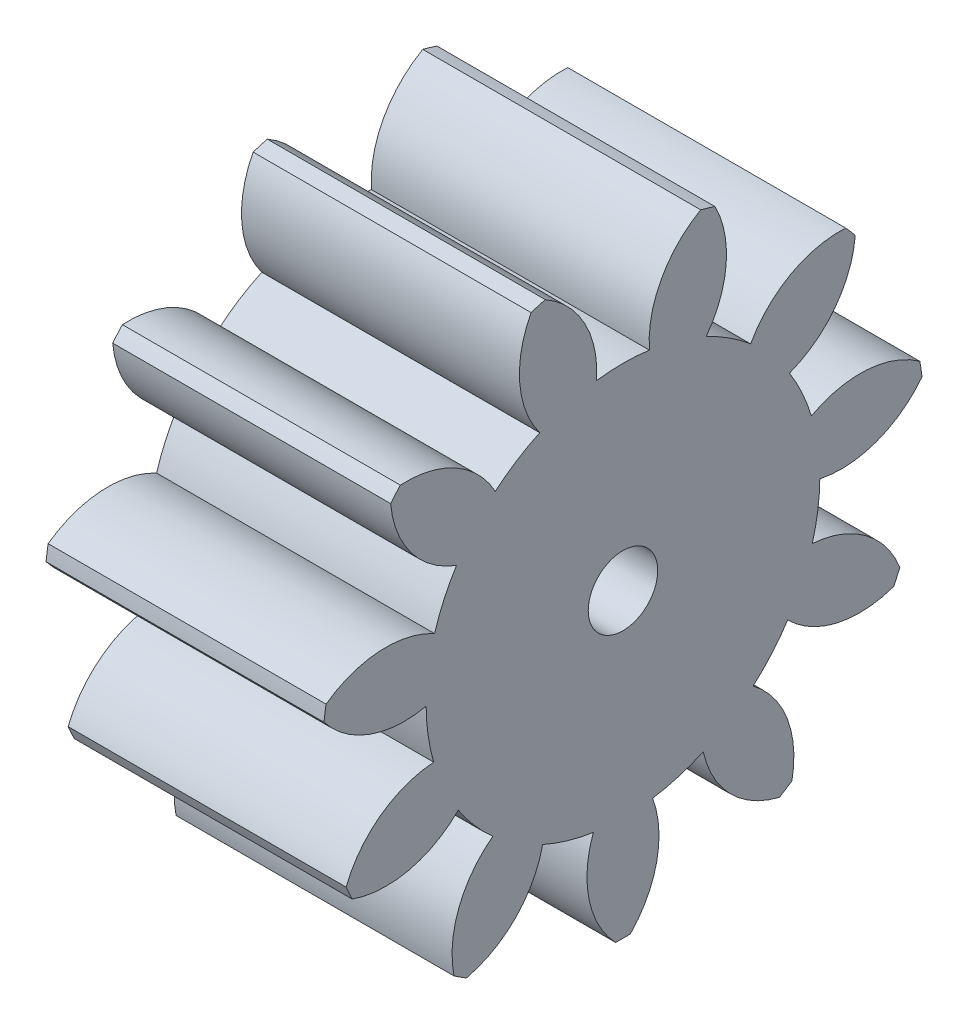
from build123d import *

# Parameters (mm, degrees)
BASPROSKE_W     = 12
BASPROSKE_H     = 13
TOOTHCUT_DEPTH  = 22.9544984
TEETHCUTS_COUNT = 11
TEETHCUTS_ANGLE = 327.272727273
BORSKE_R        = 1.5
BORE_DEPTH      = 50.0000508


with BuildPart() as part:
    # BasProSke → Base-Revolve (revolve)
    with BuildSketch(Plane(origin=(0, 0, 0), x_dir=(1, 0, 0), z_dir=(0, 1, 0)), mode=Mode.PRIVATE) as base_revolve_sk:
        with Locations((6, 6.5)):
            Rectangle(BASPROSKE_W, BASPROSKE_H)
    revolve(base_revolve_sk.sketch.rotate(Axis((-10, 0, 0), (1, 0, 0)), 180), axis=Axis((-10, 0, 0), (1, 0, 0)))

    # TooCutSke → ToothCut (cut, through all)
    with BuildSketch(Plane(origin=(0, 0, 0), x_dir=(0, 0, -1), z_dir=(1, 0, 0))):
        with BuildLine():
            ThreePointArc((1.139858048, 8.422216135), (0, 8.499), (-1.139858048, 8.422216135))
            ThreePointArc((-1.139858048, 8.422216135), (-1.658602184, 10.826907356), (-3.387115532, 12.577300725))
            ThreePointArc((-3.387115532, 12.577300725), (0, 13.0254), (3.387115532, 12.577300725))
            ThreePointArc((3.387115532, 12.577300725), (1.658602184, 10.826907356), (1.139858048, 8.422216135))
        make_face()
    toothcut = extrude(amount=TOOTHCUT_DEPTH, mode=Mode.SUBTRACT)

    # TeethCuts: ToothCut ×11 about axis
    teethcuts_axis = Axis((-10, 0, 0), (1, 0, 0))
    for i in range(1, TEETHCUTS_COUNT):
        add(toothcut.rotate(teethcuts_axis, i * TEETHCUTS_ANGLE / (TEETHCUTS_COUNT - 1)), mode=Mode.SUBTRACT)

    # BorSke → Bore (cut, symmetric)
    with BuildSketch(Plane(origin=(0, 0, 0), x_dir=(0, 0, -1), z_dir=(1, 0, 0))):
        with Locations(Location((0, 0, 0), (0, 0, 180))):
            Circle(BORSKE_R)
    extrude(amount=BORE_DEPTH, both=True, mode=Mode.SUBTRACT)


solid = part.part
